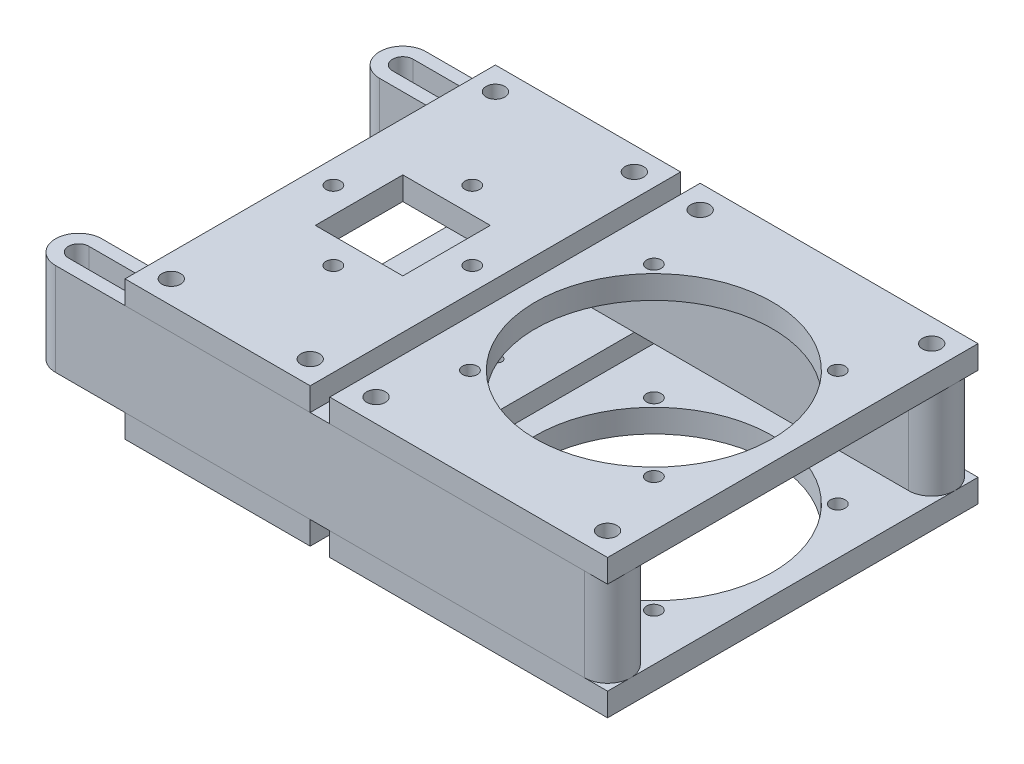
from build123d import *

# Parameters (mm, degrees)
BOSS_EXTRUDE1_START   = 19.05
SKETCH2_W             = 76.2
SKETCH2_H             = 101.6
SKETCH2_R             = 32.5
BOSS_EXTRUDE1_DEPTH   = 6.35
SKETCH2_W_2           = 50.8
BOSS_EXTRUDE1_2_DEPTH = 6.35
SKETCH3_W             = 24
SKETCH3_H             = 24
CUT_EXTRUDE1_DEPTH    = 6.35
SKETCH4_R             = 11.176
CUT_EXTRUDE2_DEPTH    = 6.35
SKETCH5_R             = 1.25
CUT_EXTRUDE3_DEPTH    = 6.35
SKETCH6_R             = 2.5527
SKETCH6_R_2           = 2.0193
CUT_EXTRUDE4_DEPTH    = 39.1
SKETCH7_R             = 2.0193
CUT_EXTRUDE5_DEPTH    = 6.35
SKETCH8_R             = 2.5527
BOSS_EXTRUDE2_DEPTH   = 25.4
BOSS_EXTRUDE2_2_DEPTH = 25.4


with BuildPart() as part:
    # Sketch2 → Boss-Extrude1 (new body)
    with BuildSketch(Plane(origin=(0, 0, 0), x_dir=(1, 0, 0), z_dir=(0, 1, 0)).offset(BOSS_EXTRUDE1_START)):
        Rectangle(SKETCH2_W, SKETCH2_H)
        Circle(SKETCH2_R, mode=Mode.SUBTRACT)
    extrude(amount=-BOSS_EXTRUDE1_DEPTH)


with BuildPart() as body_2:
    # Sketch2 → Boss-Extrude1 2 (new body)
    with BuildSketch(Plane(origin=(0, 0, 0), x_dir=(1, 0, 0), z_dir=(0, 1, 0)).offset(BOSS_EXTRUDE1_START)):
        with Locations((-68.86194, 0)):
            Rectangle(SKETCH2_W_2, SKETCH2_H)
    extrude(amount=-BOSS_EXTRUDE1_2_DEPTH)


with BuildPart() as body_3:
    # Mirror1: mirrored copy
    add(part.part.mirror(Plane.ZX))


with BuildPart() as body_4:
    # Mirror1 2: mirrored copy
    add(body_2.part.mirror(Plane.ZX))

    # Sketch4 → Cut-Extrude2 (cut)
    with BuildSketch(Plane.XZ.offset(19.05)):
        with Locations((-68.86194, 0)):
            Circle(SKETCH4_R)
    extrude(amount=-CUT_EXTRUDE2_DEPTH, mode=Mode.SUBTRACT)

    # Sketch5 → Cut-Extrude3 (cut)
    with BuildSketch(Plane.XZ.offset(19.05)):
        with Locations((-81.86674, 13.0048)):
            Circle(SKETCH5_R)
        with Locations((-55.85714, 13.0048)):
            Circle(SKETCH5_R)
        with Locations((-55.85714, -13.0048)):
            Circle(SKETCH5_R)
        with Locations((-81.86674, -13.0048)):
            Circle(SKETCH5_R)
    extrude(amount=-CUT_EXTRUDE3_DEPTH, mode=Mode.SUBTRACT)


with BuildPart() as body_2_1:
    add(body_2.part)

    # Sketch3 → Cut-Extrude1 (cut)
    with BuildSketch(Plane(origin=(0, 19.05, 0), x_dir=(1, 0, 0), z_dir=(0, 1, 0))):
        with Locations((-68.86194, 0)):
            Rectangle(SKETCH3_W, SKETCH3_H)
    extrude(amount=-CUT_EXTRUDE1_DEPTH, mode=Mode.SUBTRACT)


with BuildPart() as cut_extrude4_tool:
    # Sketch6 → Cut-Extrude4 (new body, through all)
    with BuildSketch(Plane(origin=(0, 19.05, 0), x_dir=(1, 0, 0), z_dir=(0, 1, 0))):
        with Locations((-31.75, 44.45)):
            Circle(SKETCH6_R)
        with Locations((31.75, 44.45)):
            Circle(SKETCH6_R)
        with Locations((31.75, -44.45)):
            Circle(SKETCH6_R)
        with Locations((-31.75, -44.45)):
            Circle(SKETCH6_R)
        with Locations((-25.226034419, 25.226034419)):
            Circle(SKETCH6_R_2)
        with Locations((25.226034419, 25.226034419)):
            Circle(SKETCH6_R_2)
        with Locations((25.226034419, -25.226034419)):
            Circle(SKETCH6_R_2)
        with Locations((-25.226034419, -25.226034419)):
            Circle(SKETCH6_R_2)
        with Locations((-49.81194, -44.45)):
            Circle(SKETCH6_R)
        with Locations((-49.81194, 44.45)):
            Circle(SKETCH6_R)
        with Locations((-87.91194, -44.45)):
            Circle(SKETCH6_R)
        with Locations((-87.91194, 44.45)):
            Circle(SKETCH6_R)
    extrude(amount=-CUT_EXTRUDE4_DEPTH)


with BuildPart() as part_1:
    add(part.part)

    # Cut-Extrude4: cut by cut_extrude4_tool
    add(cut_extrude4_tool.part, mode=Mode.SUBTRACT)


with BuildPart() as body_2_2:
    add(body_2_1.part)

    # Cut-Extrude4: cut by cut_extrude4_tool
    add(cut_extrude4_tool.part, mode=Mode.SUBTRACT)

    # Sketch7 → Cut-Extrude5 (cut)
    with BuildSketch(Plane(origin=(0, 19.05, 0), x_dir=(1, 0, 0), z_dir=(0, 1, 0))):
        with Locations((-68.86194, 19.05)):
            Circle(SKETCH7_R)
        with Locations((-68.86194, -19.05)):
            Circle(SKETCH7_R)
        with Locations((-87.91194, 0)):
            Circle(SKETCH7_R)
        with Locations((-49.81194, 0)):
            Circle(SKETCH7_R)
    extrude(amount=-CUT_EXTRUDE5_DEPTH, mode=Mode.SUBTRACT)


with BuildPart() as body_3_1:
    add(body_3.part)

    # Cut-Extrude4: cut by cut_extrude4_tool
    add(cut_extrude4_tool.part, mode=Mode.SUBTRACT)


with BuildPart() as body_4_1:
    add(body_4.part)

    # Cut-Extrude4: cut by cut_extrude4_tool
    add(cut_extrude4_tool.part, mode=Mode.SUBTRACT)


with BuildPart() as body_5:
    # Sketch8 → Boss-Extrude2 (new body)
    with BuildSketch(Plane(origin=(0, -12.7, 0), x_dir=(1, 0, 0), z_dir=(0, 1, 0))):
        with BuildLine():
            Line((31.75, -50.8), (-113.31194, -50.8))
            ThreePointArc((-113.31194, -50.8), (-119.66194, -44.45), (-113.31194, -38.1))
            Line((-113.31194, -38.1), (31.75, -38.1))
            ThreePointArc((31.75, -38.1), (38.1, -44.45), (31.75, -50.8))
        make_face()
        with Locations((-31.75, -44.45)):
            Circle(SKETCH8_R, mode=Mode.SUBTRACT)
        with Locations((31.75, -44.45)):
            Circle(SKETCH8_R, mode=Mode.SUBTRACT)
        with BuildLine():
            Line((-49.81194, -47.244), (-113.31194, -47.244))
            ThreePointArc((-113.31194, -47.244), (-116.10594, -44.45), (-113.31194, -41.656))
            Line((-113.31194, -41.656), (-49.81194, -41.656))
            ThreePointArc((-49.81194, -41.656), (-47.01794, -44.45), (-49.81194, -47.244))
        make_face(mode=Mode.SUBTRACT)
    extrude(amount=BOSS_EXTRUDE2_DEPTH)


with BuildPart() as body_6:
    # Sketch8 → Boss-Extrude2 2 (new body)
    with BuildSketch(Plane(origin=(0, -12.7, 0), x_dir=(1, 0, 0), z_dir=(0, 1, 0))):
        with BuildLine():
            Line((31.75, 38.1), (-113.31194, 38.1))
            ThreePointArc((-113.31194, 38.1), (-119.66194, 44.45), (-113.31194, 50.8))
            Line((-113.31194, 50.8), (31.75, 50.8))
            ThreePointArc((31.75, 50.8), (38.1, 44.45), (31.75, 38.1))
        make_face()
        with Locations((-31.75, 44.45)):
            Circle(SKETCH8_R, mode=Mode.SUBTRACT)
        with Locations((31.75, 44.45)):
            Circle(SKETCH8_R, mode=Mode.SUBTRACT)
        with BuildLine():
            Line((-49.81194, 41.656), (-113.31194, 41.656))
            ThreePointArc((-113.31194, 41.656), (-116.10594, 44.45), (-113.31194, 47.244))
            Line((-113.31194, 47.244), (-49.81194, 47.244))
            ThreePointArc((-49.81194, 47.244), (-47.01794, 44.45), (-49.81194, 41.656))
        make_face(mode=Mode.SUBTRACT)
    extrude(amount=BOSS_EXTRUDE2_2_DEPTH)


solid = Compound([part_1.part, body_2_2.part, body_3_1.part, body_4_1.part, body_5.part, body_6.part])
